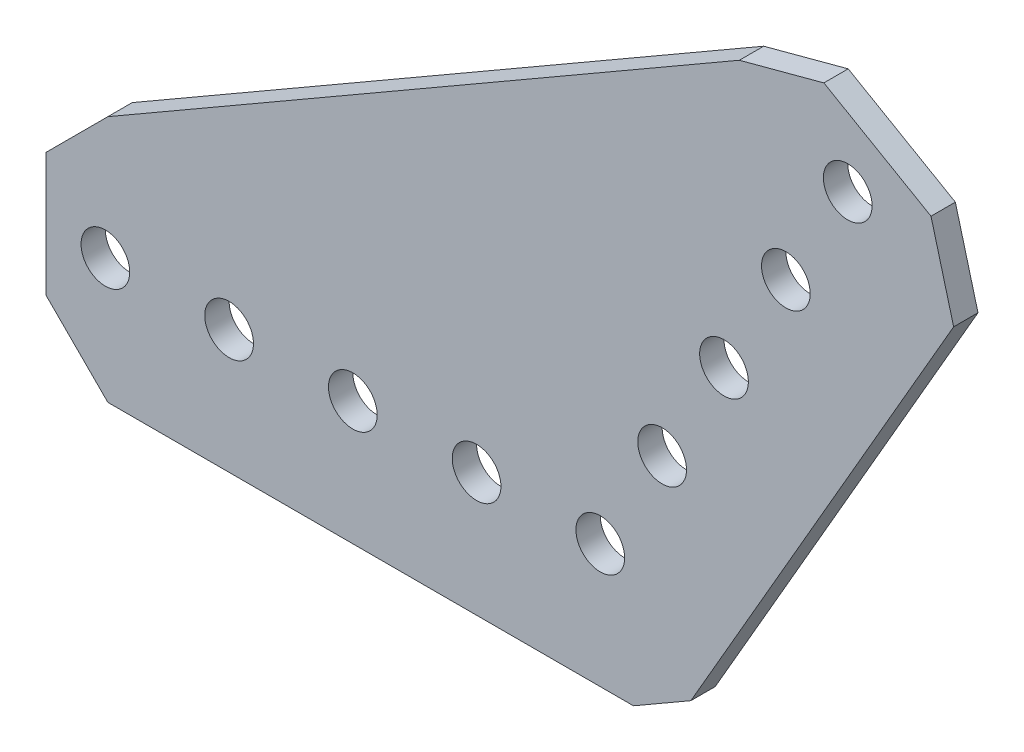
from build123d import *

# Parameters (mm, degrees)
SKETCH1_R           = 2.5
BOSS_EXTRUDE1_DEPTH = 2.5


with BuildPart() as part:
    # Sketch1 → Boss-Extrude1 (new body)
    with BuildSketch(Plane(origin=(0, 0, -1.25), x_dir=(-1, 0, 0), z_dir=(0, 0, -1))):
        Polygon((-3.402954744, -12.7), (50.546, -12.7), (56.896, -6.35), (56.896, 6.35), (50.546, 12.7), (-14.274477372, 50.12412006), (-22.948738686, 52.448381374), (-33.947261314, 46.098381374), (-36.271522628, 37.42412006), (-9.297045256, -9.297045256), align=None)
        with Locations((12.7, 0)):
            Circle(SKETCH1_R, mode=Mode.SUBTRACT)
        with Locations((25.4, 0)):
            Circle(SKETCH1_R, mode=Mode.SUBTRACT)
        Circle(SKETCH1_R, mode=Mode.SUBTRACT)
        with Locations((50.8, 0)):
            Circle(SKETCH1_R, mode=Mode.SUBTRACT)
        with Locations((38.1, 0)):
            Circle(SKETCH1_R, mode=Mode.SUBTRACT)
        with Locations((-25.4, 43.994090512)):
            Circle(SKETCH1_R, mode=Mode.SUBTRACT)
        with Locations((-19.05, 32.995567884)):
            Circle(SKETCH1_R, mode=Mode.SUBTRACT)
        with Locations((-12.7, 21.997045256)):
            Circle(SKETCH1_R, mode=Mode.SUBTRACT)
        with Locations((-6.35, 10.998522628)):
            Circle(SKETCH1_R, mode=Mode.SUBTRACT)
    extrude(amount=-BOSS_EXTRUDE1_DEPTH)


solid = part.part
